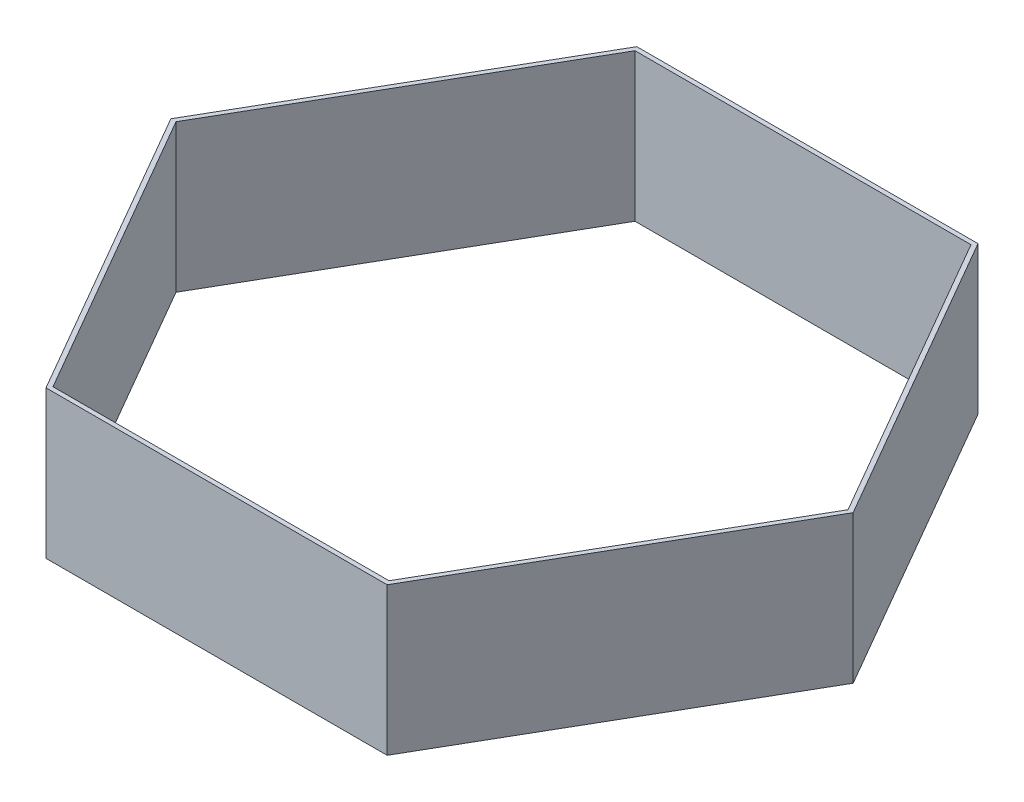
from build123d import *

# Parameters (mm, degrees)
SALIENTE_EXTRUIR1_DEPTH = 100


with BuildPart() as part:
    # Croquis1 → Saliente-Extruir1 (new body)
    with BuildSketch(Plane(origin=(0, 0, 0), x_dir=(1, 0, 0), z_dir=(0, 1, 0))):
        Polygon((-115.470053838, -200), (115.470053838, -200), (230.940107676, 0), (115.470053838, 200), (-115.470053838, 200), (-230.940107676, 0), align=None)
        Polygon((113.73800303, -197), (227.476006061, 0), (113.73800303, 197), (-113.73800303, 197), (-227.476006061, 0), (-113.73800303, -197), align=None, mode=Mode.SUBTRACT)
    extrude(amount=SALIENTE_EXTRUIR1_DEPTH)


solid = part.part
